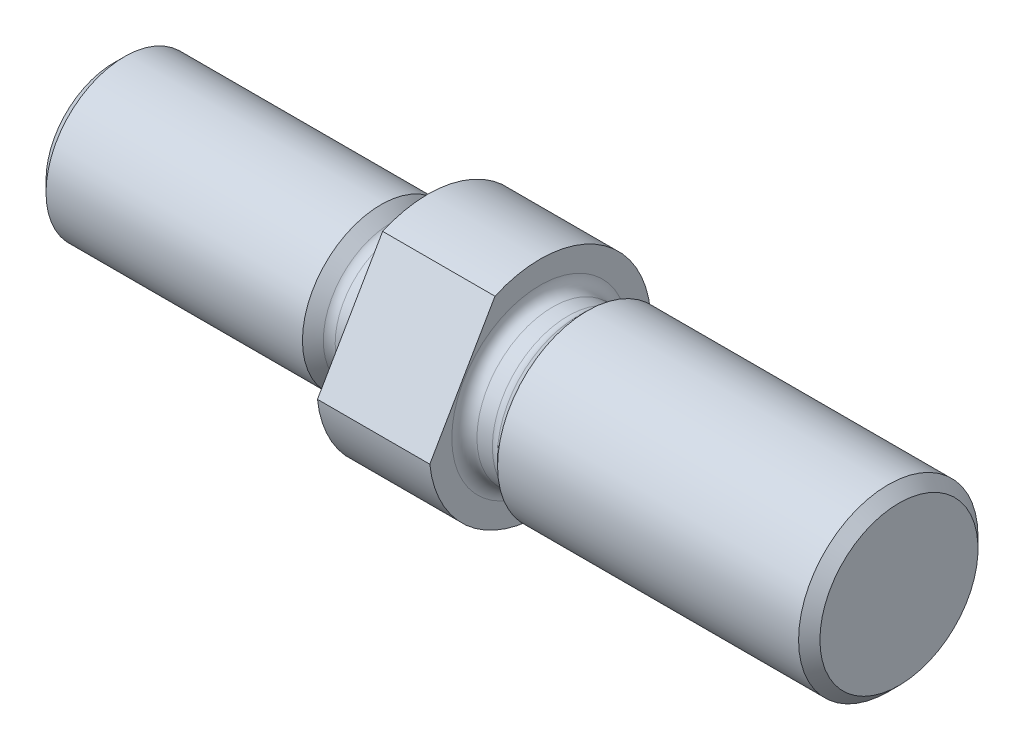
from build123d import *

# Parameters (mm, degrees)
CUT_EXTRUDE1_DEPTH = 31.4452


with BuildPart() as part:
    # Sketch1 → Revolve1 (revolve)
    with BuildSketch(Plane.XY):
        with BuildLine():
            Line((0, 0), (0, 4.79425))
            Line((0, 4.79425), (0.762, 5.55625))
            Line((0.762, 5.55625), (18.912356192, 5.55625))
            Line((18.912356192, 5.55625), (19.651103096, 4.817503096))
            ThreePointArc((19.651103096, 4.817503096), (19.923034747, 4.635804176), (20.2438, 4.572))
            Line((20.2438, 4.572), (21.3868, 4.572))
            ThreePointArc((21.3868, 4.572), (21.979496904, 4.817503096), (22.225, 5.4102))
            Line((22.225, 5.4102), (22.225, 7.8486))
            Line((22.225, 7.8486), (30.1752, 7.8486))
            Line((30.1752, 7.8486), (30.1752, 0))
            Line((30.1752, 0), (0, 0))
        make_face()
    revolve(axis=Axis((30.1752, 0, 0), (-1, 0, 0)))

    # Sketch3 → Revolve2 (revolve)
    with BuildSketch(Plane.XY):
        with BuildLine():
            Line((30.1752, 0), (30.1752, 6.2484))
            ThreePointArc((30.1752, 6.2484), (30.435582072, 5.619782072), (31.0642, 5.3594))
            Line((31.0642, 5.3594), (32.1564, 5.3594))
            ThreePointArc((32.1564, 5.3594), (32.496605571, 5.427071096), (32.785017928, 5.619782072))
            Line((32.785017928, 5.619782072), (33.515235857, 6.35))
            Line((33.515235857, 6.35), (54.81955, 6.35))
            Line((54.81955, 6.35), (55.5752, 5.59435))
            Line((55.5752, 5.59435), (55.5752, 0))
            Line((55.5752, 0), (30.1752, 0))
        make_face()
    revolve(axis=Axis((55.5752, 0, 0), (-1, 0, 0)))

    # Sketch2 → Cut-Extrude1 (cut)
    with BuildSketch(Plane(origin=(0, 0, 0), x_dir=(0, 0, -1), z_dir=(1, 0, 0))):
        Polygon((-21.859138511, -5.857138511), (5.857138511, -21.859138511), (21.859138511, 5.857138511), (-5.857138511, 21.859138511), align=None)
        with BuildLine():
            Line((2.227168484, -8.842431029), (8.771354144, 2.492431029))
            ThreePointArc((8.771354144, 2.492431029), (4.5593, 7.896939247), (-2.227168484, 8.842431029))
            Line((-2.227168484, 8.842431029), (-8.771354144, -2.492431029))
            ThreePointArc((-8.771354144, -2.492431029), (-4.5593, -7.896939247), (2.227168484, -8.842431029))
        make_face(mode=Mode.SUBTRACT)
    extrude(amount=CUT_EXTRUDE1_DEPTH, mode=Mode.SUBTRACT)


solid = part.part
